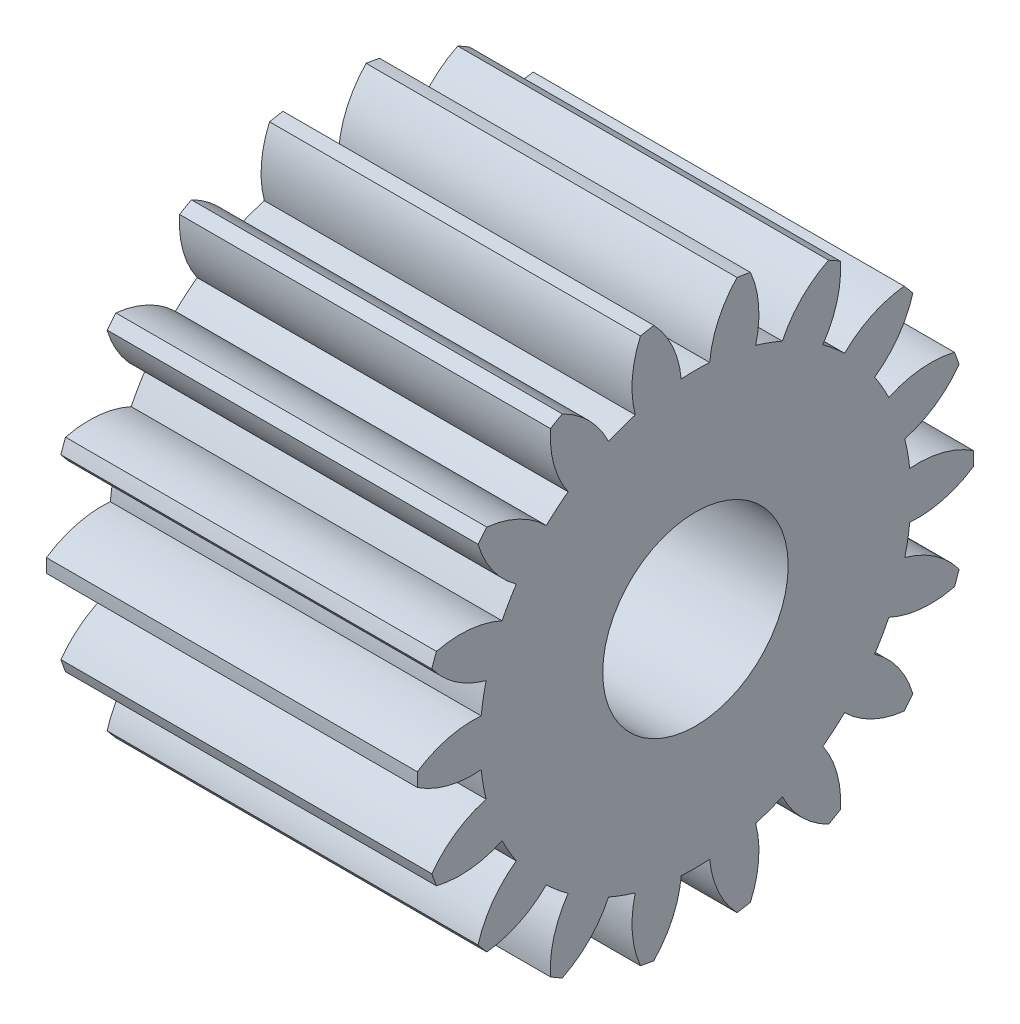
from build123d import *

# Parameters (mm, degrees)
BASPROSKE_W        = 8
BASPROSKE_H        = 6
TOOTHCUT_DEPTH     = 12.66190379
TEETHCUTS_COUNT    = 18
TEETHCUTS_ANGLE    = 340
BORSKE_R           = 0.5
BORE_DEPTH         = 50.0000508
SKETCH1_R          = 2
CUT_EXTRUDE1_DEPTH = 12.627390673


with BuildPart() as part:
    # BasProSke → Base-Revolve (revolve)
    with BuildSketch(Plane(origin=(0, 0, 0), x_dir=(1, 0, 0), z_dir=(0, 1, 0)), mode=Mode.PRIVATE) as base_revolve_sk:
        with Locations((4, 3)):
            Rectangle(BASPROSKE_W, BASPROSKE_H)
    revolve(base_revolve_sk.sketch.rotate(Axis((-10, 0, 0), (1, 0, 0)), 180), axis=Axis((-10, 0, 0), (1, 0, 0)))

    # TooCutSke → ToothCut (cut, through all)
    with BuildSketch(Plane(origin=(0, 0, 0), x_dir=(0, 0, -1), z_dir=(1, 0, 0))):
        with BuildLine():
            ThreePointArc((0.306649621, 4.638875619), (0, 4.649), (-0.306649621, 4.638875619))
            ThreePointArc((-0.306649621, 4.638875619), (-0.498605842, 5.349852231), (-0.918258882, 5.955018538))
            ThreePointArc((-0.918258882, 5.955018538), (0, 6.0254), (0.918258882, 5.955018538))
            ThreePointArc((0.918258882, 5.955018538), (0.498605842, 5.349852231), (0.306649621, 4.638875619))
        make_face()
    toothcut = extrude(amount=TOOTHCUT_DEPTH, mode=Mode.SUBTRACT)

    # TeethCuts: ToothCut ×18 about axis
    teethcuts_axis = Axis((-10, 0, 0), (1, 0, 0))
    for i in range(1, TEETHCUTS_COUNT):
        add(toothcut.rotate(teethcuts_axis, i * TEETHCUTS_ANGLE / (TEETHCUTS_COUNT - 1)), mode=Mode.SUBTRACT)

    # BorSke → Bore (cut, symmetric)
    with BuildSketch(Plane(origin=(0, 0, 0), x_dir=(0, 0, -1), z_dir=(1, 0, 0))):
        with Locations(Location((0, 0, 0), (0, 0, 180))):
            Circle(BORSKE_R)
    extrude(amount=BORE_DEPTH, both=True, mode=Mode.SUBTRACT)

    # Sketch1 → Cut-Extrude1 (cut, through all)
    with BuildSketch(Plane(origin=(8, 0, 0), x_dir=(0, 0, -1), z_dir=(1, 0, 0))):
        Circle(SKETCH1_R)
    extrude(amount=-CUT_EXTRUDE1_DEPTH, mode=Mode.SUBTRACT)


solid = part.part
